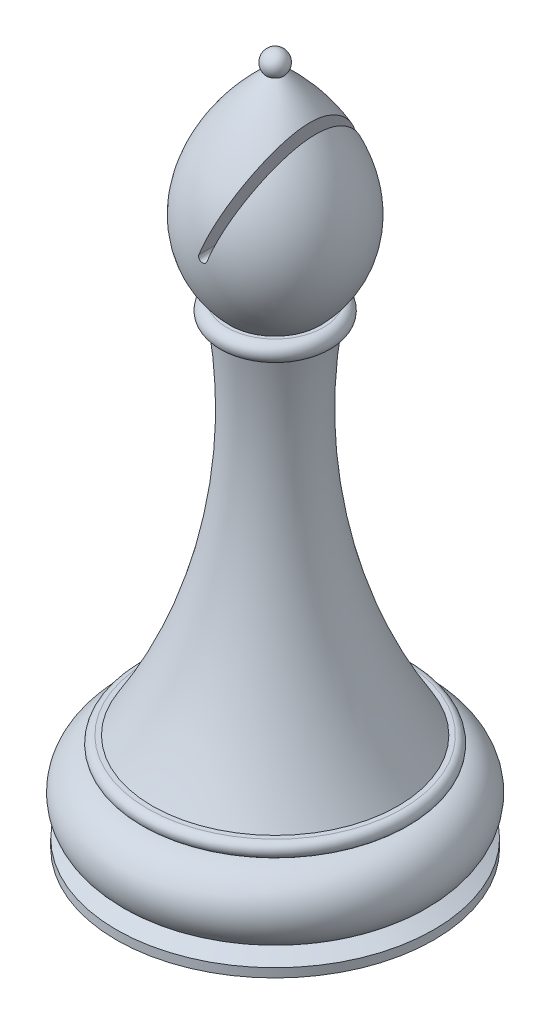
from build123d import *

# Parameters (mm, degrees)
CUT_EXTRUDE2_DEPTH      = 16.851556004
CUT_EXTRUDE2_DEPTH_BACK = 16.851556004


with BuildPart() as part:
    # Sketch1 → Revolve2 (revolve)
    with BuildSketch(Plane.XY):
        with BuildLine():
            Line((0, 57.140903962), (0, 0))
            Line((0, 0), (12.045922989, 0))
            ThreePointArc((12.045922989, 0), (5.251378202, 16.94092408), (4.657394802, 35.183948261))
            ThreePointArc((4.657394802, 35.183948261), (5.627418026, 36.043696722), (4.729445697, 36.978447045))
            Line((4.729445697, 36.978447045), (4.389608164, 36.978447045))
            add(Edge.make_bspline(
                [(0.850007783, 56.39158134), (8.657410118, 49.270274861), (9.212929783, 41.803211627), (4.389608164, 36.978447045)],
                knots=[0.026652519, 0.026652519, 0.026652519, 0.026652519, 0.785114143, 0.785114143, 0.785114143, 0.785114143], degree=3))
            add(Edge.make_bspline(
                [(0, 57.140903962), (0.292344998, 56.891643147), (0.575653834, 56.64182572), (0.850007783, 56.39158134)],
                knots=[0, 0, 0, 0, 0.026652519, 0.026652519, 0.026652519, 0.026652519], degree=3))
        make_face()
        with BuildLine():
            Line((15.56268383, -8.751500195), (13.893883706, -7.960560004))
            ThreePointArc((13.893883706, -7.960560004), (15.773602868, -4.136267719), (12.478125528, -1.43471544))
            Line((12.478125528, -1.43471544), (12.478125528, -1.42836544))
            ThreePointArc((12.478125528, -1.42836544), (13.215841354, -0.726095063), (12.5015625, 0))
            Line((12.5015625, 0), (0, 0))
            Line((0, 0), (0, -9.621899232))
            Line((0, -9.621899232), (15.56268383, -9.621899232))
            Line((15.56268383, -9.621899232), (15.56268383, -8.751500195))
        make_face()
        with BuildLine():
            Line((0, 58.274040151), (0, 57.140903962))
            add(Edge.make_bspline(
                [(0, 57.140903962), (0.292344998, 56.891643147), (0.575653834, 56.64182572), (0.850007783, 56.39158134)],
                knots=[0, 0, 0, 0, 0.026652519, 0.026652519, 0.026652519, 0.026652519], degree=3))
            ThreePointArc((0.850007783, 56.39158134), (1.032734768, 57.607226298), (0, 58.274040151))
        make_face()
    revolve(axis=Axis((0, 0, 0), (0, -1, 0)))

    # Sketch2 → Cut-Extrude2 (cut, two sides)
    with BuildSketch(Plane.XY) as cut_extrude2_sk:
        with BuildLine():
            Line((3.418341943, 53.738221663), (0, 44.545930935))
            ThreePointArc((0, 44.545930935), (0.23049432, 44.042518225), (0.73390703, 44.273012546))
            Line((0.73390703, 44.273012546), (3.991277435, 53.032433421))
            add(Edge.make_bspline(
                [(3.991277435, 53.032433421), (3.807835448, 53.267599643), (3.616879106, 53.502897736), (3.418341943, 53.738221663)],
                knots=[0.639700811, 0.639700811, 0.639700811, 0.639700811, 0.664624856, 0.664624856, 0.664624856, 0.664624856], degree=3))
        make_face()
    extrude(amount=CUT_EXTRUDE2_DEPTH, mode=Mode.SUBTRACT)
    extrude(cut_extrude2_sk.sketch, amount=-CUT_EXTRUDE2_DEPTH_BACK, mode=Mode.SUBTRACT)


solid = part.part
